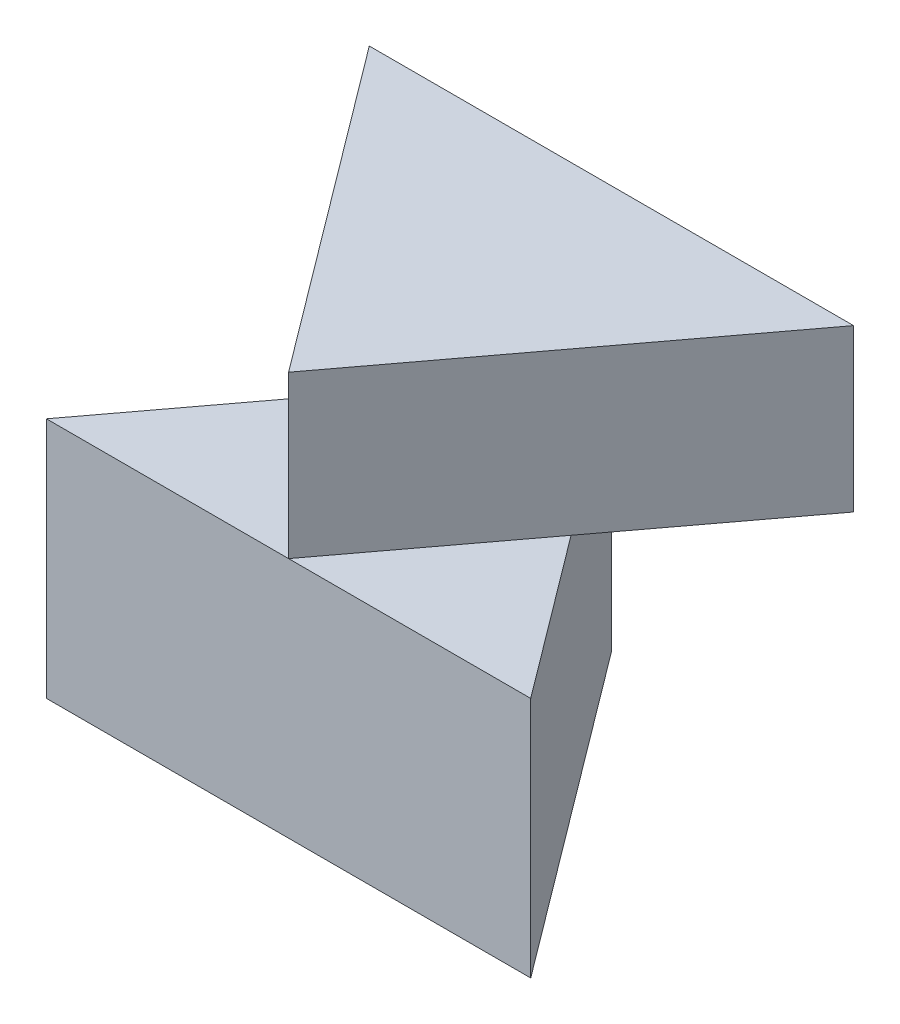
from build123d import *

# Parameters (mm, degrees)
BOSS_EXTRUDE1_DEPTH = 3
BOSS_EXTRUDE2_DEPTH = 2


with BuildPart() as part:
    # Sketch1 → Boss-Extrude1 (new body)
    with BuildSketch(Plane(origin=(0, 0, 0), x_dir=(1, 0, 0), z_dir=(0, 1, 0))):
        Polygon((0, 4), (-3, 0), (3, 0), align=None)
    extrude(amount=BOSS_EXTRUDE1_DEPTH)

    # Sketch2 → Boss-Extrude2 (add)
    with BuildSketch(Plane(origin=(0, 3, 0), x_dir=(1, 0, 0), z_dir=(0, 1, 0))):
        Polygon((0, 0), (-3, 4), (3, 4), align=None)
    extrude(amount=BOSS_EXTRUDE2_DEPTH)


solid = part.part
